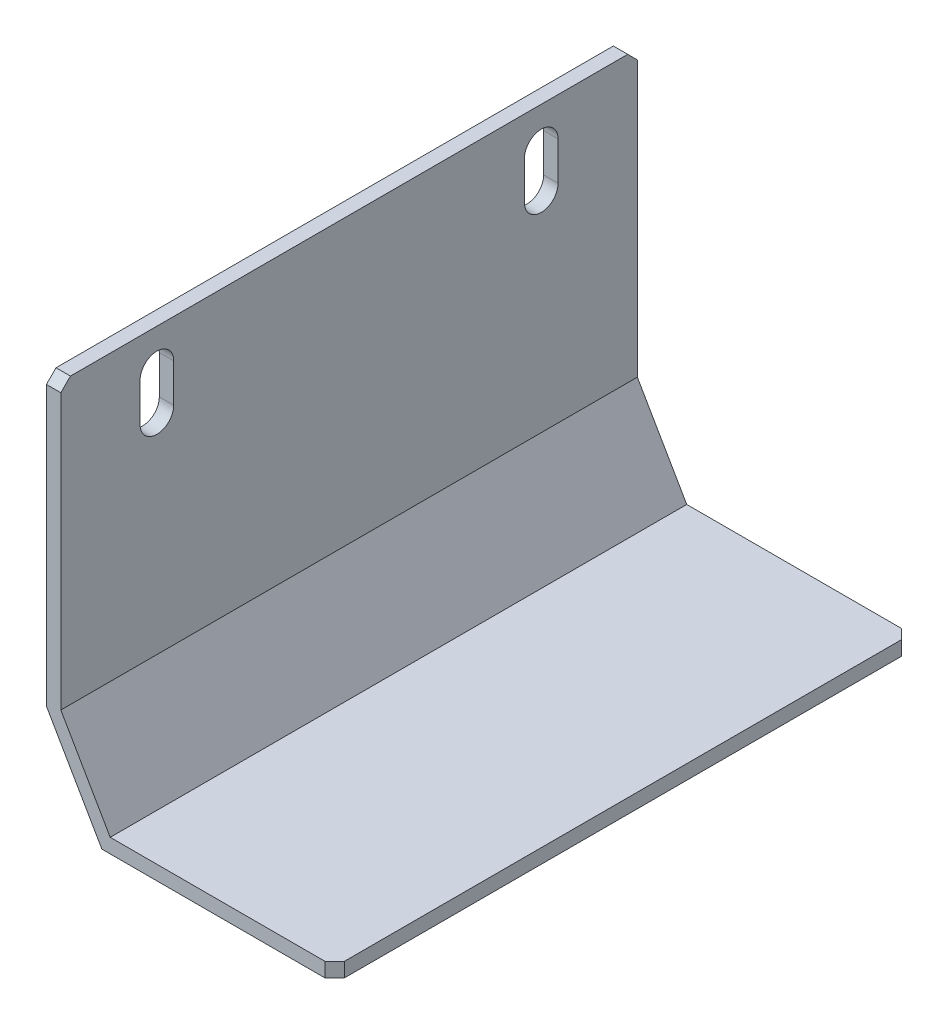
from build123d import *

# Parameters (mm, degrees)
BOSS_EXTRUDE1_DEPTH = 60
CUT_EXTRUDE1_DEPTH  = 60
CHAMFER1_SIZE       = 1


with BuildPart() as part:
    # Sketch1 → Boss-Extrude1 (new body)
    with BuildSketch(Plane.XY):
        Polygon((-13.372093023, -14.244186047), (-7.598590331, -24.244186047), (16.627906977, -24.244186047), (16.627906977, -22.744186047), (-6.732564928, -22.744186047), (-11.872093023, -13.842262258), (-11.872093023, 15.755813953), (-13.372093023, 15.755813953), align=None)
    extrude(amount=BOSS_EXTRUDE1_DEPTH)

    # Sketch3 → Cut-Extrude1 (cut)
    with BuildSketch(Plane.ZY.offset(13.372093023)):
        with BuildLine():
            Line((8.25, 11.755813953), (8.25, 7.755813953))
            ThreePointArc((8.25, 7.755813953), (10, 6.005813953), (11.75, 7.755813953))
            Line((11.75, 7.755813953), (11.75, 11.755813953))
            ThreePointArc((11.75, 11.755813953), (10, 13.505813953), (8.25, 11.755813953))
        make_face()
        with BuildLine():
            Line((48.25, 11.755813953), (48.25, 7.755813953))
            ThreePointArc((48.25, 7.755813953), (50, 6.005813953), (51.75, 7.755813953))
            Line((51.75, 7.755813953), (51.75, 11.755813953))
            ThreePointArc((51.75, 11.755813953), (50, 13.505813953), (48.25, 11.755813953))
        make_face()
    extrude(amount=-CUT_EXTRUDE1_DEPTH, mode=Mode.SUBTRACT)

    # Chamfer1
    chamfer1_edges = [part.edges().sort_by_distance(p)[0] for p in [
        (16.627906977, -23.494186047, 60),
        (-12.622093023, 15.755813953, 60),
        (-12.622093023, 15.755813953, 0),
        (16.627906977, -23.494186047, 0),
    ]]
    chamfer(chamfer1_edges, length=CHAMFER1_SIZE)


solid = part.part
